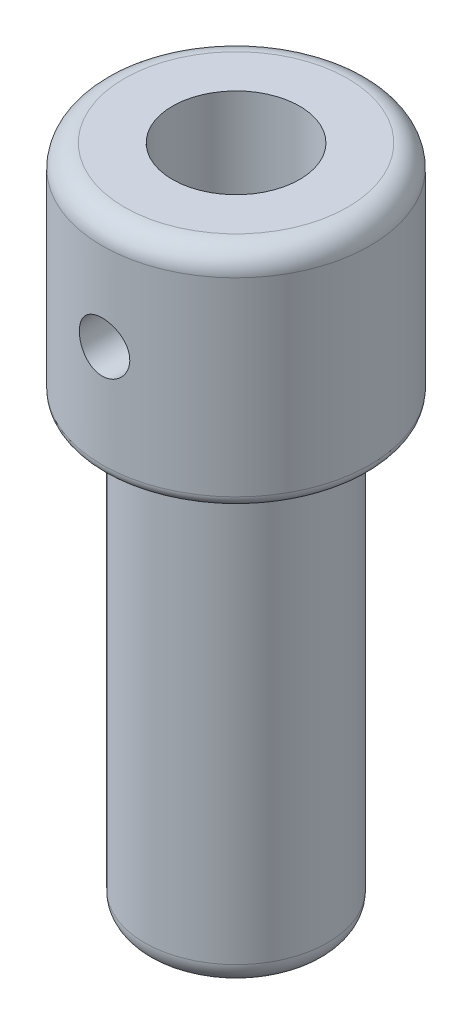
from build123d import *

# Parameters (mm, degrees)
CUT_EXTRUDE1_DEPTH      = 10
CUT_EXTRUDE1_DEPTH_BACK = 10
SKETCH2_R               = 1.1303


with BuildPart() as part:
    # Sketch1 → Revolve1 (revolve)
    with BuildSketch(Plane.XY):
        with BuildLine():
            Line((2.85, 19.132875201), (5, 19.132875201))
            ThreePointArc((5, 19.132875201), (5.707106781, 18.839981982), (6, 18.132875201))
            Line((6, 18.132875201), (6, 9.632875201))
            ThreePointArc((6, 9.632875201), (5.853553391, 9.27932181), (5.5, 9.132875201))
            Line((5.5, 9.132875201), (5.1, 9.132875201))
            ThreePointArc((5.1, 9.132875201), (4.392893219, 8.839981982), (4.1, 8.132875201))
            Line((4.1, 8.132875201), (4.1, -9.867124799))
            ThreePointArc((4.1, -9.867124799), (3.807106781, -10.57423158), (3.1, -10.867124799))
            Line((3.1, -10.867124799), (2.85, -10.867124799))
            Line((2.85, -10.867124799), (2.85, 19.132875201))
        make_face()
    revolve(axis=Axis((0, 27.883391117, 0), (0, -1, 0)))

    # Sketch2 → Cut-Extrude1 (cut, two sides: drawn at the far end of the back side and taken through both)
    with BuildSketch(Plane.XY.offset(-CUT_EXTRUDE1_DEPTH_BACK)):
        with Locations((0, 14.207956768)):
            Circle(SKETCH2_R)
    extrude(amount=CUT_EXTRUDE1_DEPTH + CUT_EXTRUDE1_DEPTH_BACK, mode=Mode.SUBTRACT)


solid = part.part
